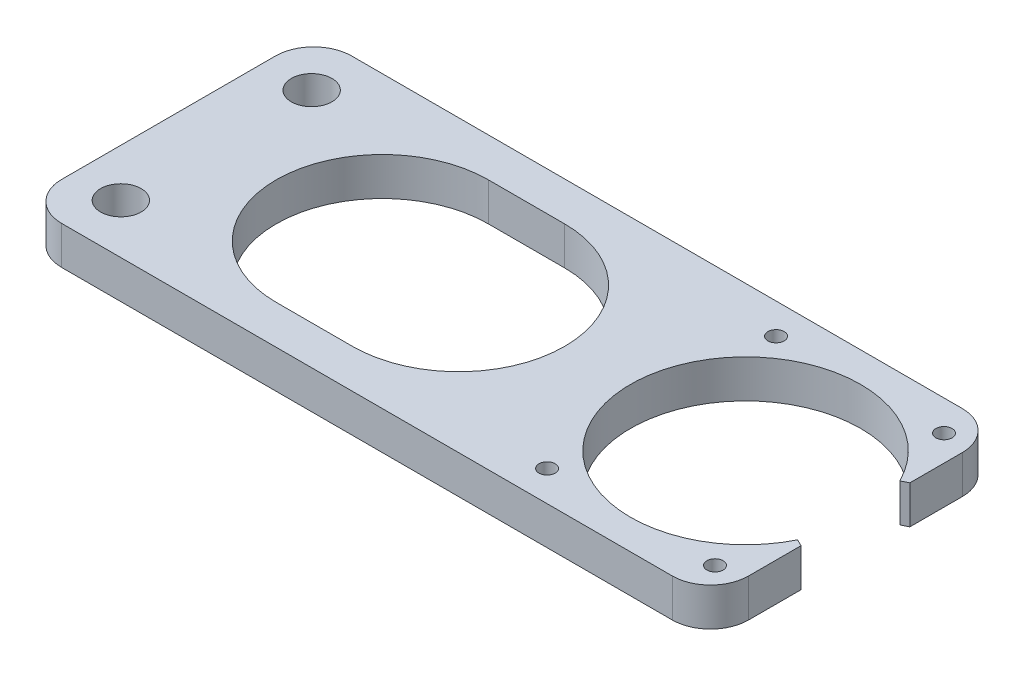
from build123d import *

# Parameters (mm, degrees)
BOSS_EXTRUDE1_DEPTH       = 6.35
FILLET1_R                 = 6.35
F_1_4_CLEARANCE_HOLE1_D   = 6.7564
TAP_DRILL_FOR_6_32_TAP1_D = 2.7051


with BuildPart() as part:
    # Sketch1 → Boss-Extrude1 (new body)
    with BuildSketch(Plane(origin=(0, 0, 0), x_dir=(1, 0, 0), z_dir=(0, 1, 0))):
        with BuildLine():
            Line((0, 0), (114.3, 0))
            Line((114.3, 0), (114.3, 15.075180871))
            Line((114.3, 15.075180871), (113.175058985, 15.632165638))
            ThreePointArc((113.175058985, 15.632165638), (76.8604, 24.13), (113.175058985, 32.627834362))
            Line((113.175058985, 32.627834362), (114.3, 33.184819129))
            Line((114.3, 33.184819129), (114.3, 48.26))
            Line((114.3, 48.26), (0, 48.26))
            Line((0, 48.26), (0, 0))
        make_face()
        with BuildLine():
            Line((35.56, 41.783), (48.26, 41.783))
            ThreePointArc((48.26, 41.783), (65.913, 24.13), (48.26, 6.477))
            Line((48.26, 6.477), (35.56, 6.477))
            ThreePointArc((35.56, 6.477), (17.907, 24.13), (35.56, 41.783))
        make_face(mode=Mode.SUBTRACT)
    extrude(amount=BOSS_EXTRUDE1_DEPTH)

    # Fillet1
    fillet1_edges = [part.edges().sort_by_distance(p)[0] for p in [
        (0, 3.175, 0),
        (0, 3.175, -48.26),
        (114.3, 3.175, -48.26),
        (114.3, 3.175, 0),
    ]]
    fillet(fillet1_edges, radius=FILLET1_R)

    # 1/4 Clearance Hole1 (through all)
    with Locations(Plane(origin=(0, 6.35, 0), x_dir=(1, 0, 0), z_dir=(0, 1, 0))):
        with Locations((7.9375, 40.005), (7.9375, 8.255)):
            Hole(F_1_4_CLEARANCE_HOLE1_D / 2)

    # Tap Drill for #6-32 Tap1 (through all)
    with Locations(Plane(origin=(0, 6.35, 0), x_dir=(1, 0, 0), z_dir=(0, 1, 0))):
        with Locations((82.042, 43.18), (109.982, 43.18), (109.982, 5.08), (82.042, 5.08), (96.012, 24.13)):
            Hole(TAP_DRILL_FOR_6_32_TAP1_D / 2)


solid = part.part
